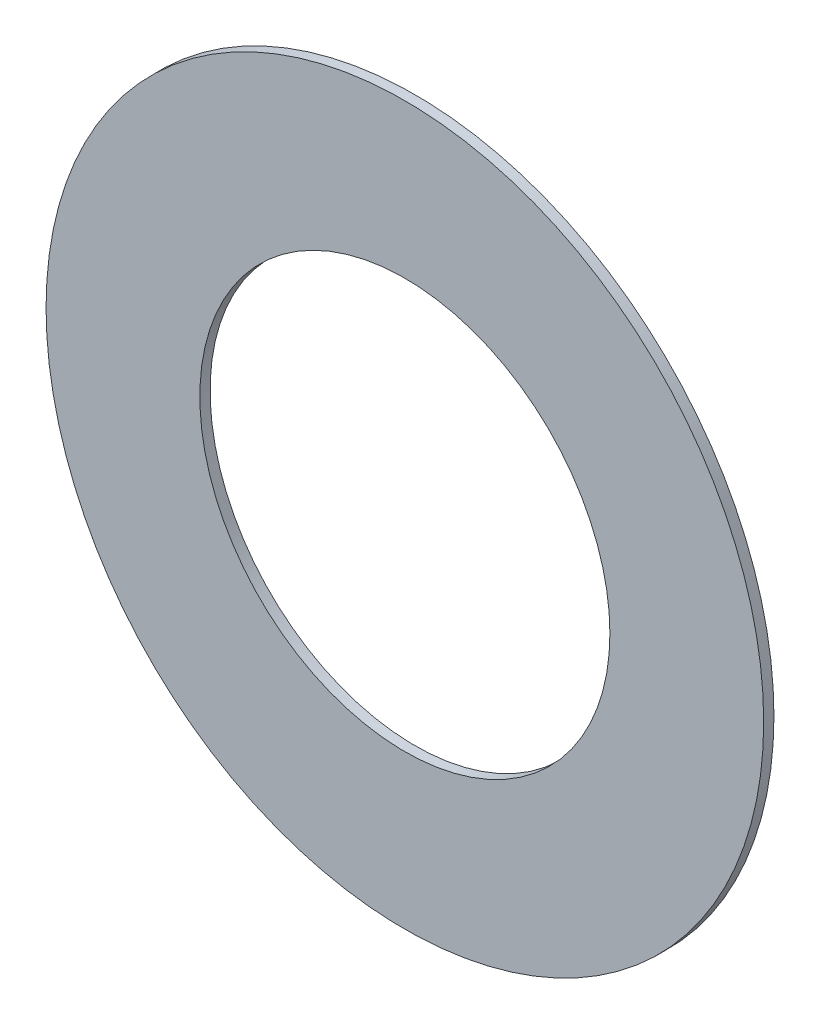
from build123d import *

# Parameters (mm, degrees)
SKETCH1_R           = 3.5
SKETCH1_R_2         = 2
BOSS_EXTRUDE1_DEPTH = 0.1


with BuildPart() as part:
    # Sketch1 → Boss-Extrude1 (new body)
    with BuildSketch(Plane.XY):
        Circle(SKETCH1_R)
        Circle(SKETCH1_R_2, mode=Mode.SUBTRACT)
    extrude(amount=BOSS_EXTRUDE1_DEPTH)


solid = part.part
